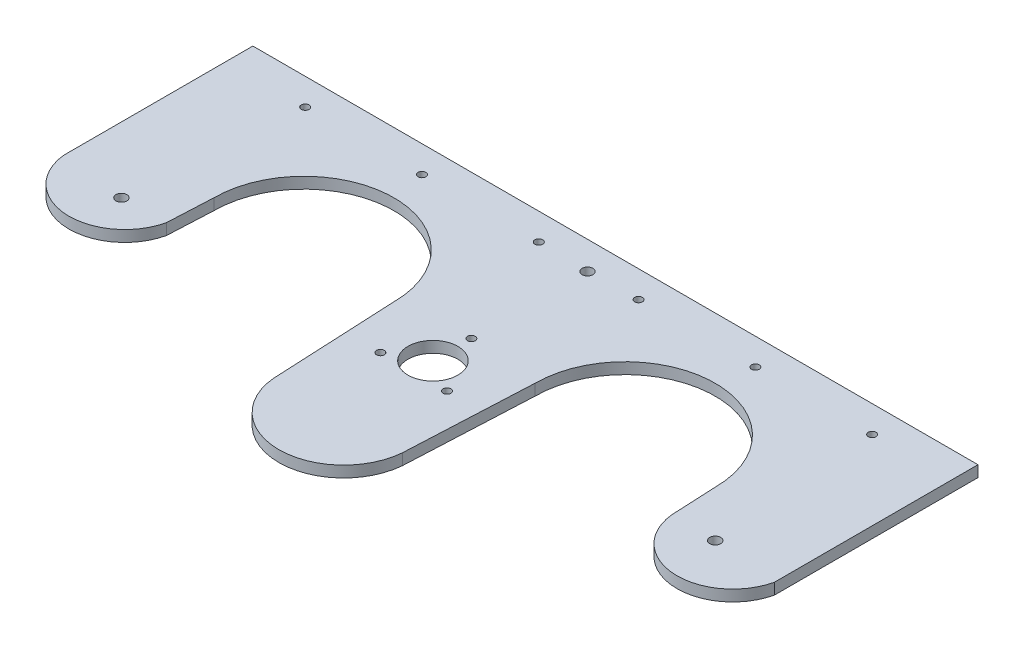
from build123d import *

# Parameters (mm, degrees)
ESQUISSE2_W                = 298
ESQUISSE2_H                = 145
BOSS_EXTRU_1_DEPTH         = 4.6
CREUX_STOCKAGE_VERRE_DEPTH = 46.6
ESQUISSE6_R                = 10.25
TROU_BILLE_DEPTH           = 5.6
ESQUISSE7_R                = 1.6
ENL_V_MAT_EXTRU_3_DEPTH    = 5.6
ENL_V_MAT_EXTRU_7_DEPTH    = 29
ESQUISSE13_R               = 2.25
ENL_V_MAT_EXTRU_9_DEPTH    = 35
ESQUISSE17_R               = 1.6
ENL_V_MAT_EXTRU_14_DEPTH   = 4.6
BOSS_EXTRU_5_DEPTH         = 4.6
ENL_V_MAT_EXTRU_15_DEPTH   = 4.6
ENL_V_MAT_EXTRU_16_DEPTH   = 4.6


with BuildPart() as part:
    # Esquisse2 → Boss.-Extru.1 (new body)
    with BuildSketch(Plane(origin=(0, 0, 0), x_dir=(1, 0, 0), z_dir=(0, 1, 0))):
        with Locations((149, 72.5)):
            Rectangle(ESQUISSE2_W, ESQUISSE2_H)
    extrude(amount=BOSS_EXTRU_1_DEPTH)

    # Esquisse3 → creux_stockage_verre (cut)
    with BuildSketch(Plane(origin=(0, 4.6, 0), x_dir=(1, 0, 0), z_dir=(0, 1, 0))):
        with BuildLine():
            Line((46, 83), (42, 0))
            Line((42, 0), (124, 0))
            Line((124, 0), (120, 83))
            ThreePointArc((120, 83), (83, 120), (46, 83))
        make_face()
        with BuildLine():
            Line((174, 0), (256, 0))
            Line((256, 0), (252, 83))
            ThreePointArc((252, 83), (215, 120), (178, 83))
            Line((178, 83), (174, 0))
        make_face()
    extrude(amount=-CREUX_STOCKAGE_VERRE_DEPTH, mode=Mode.SUBTRACT)

    # Esquisse6 → trou_bille (cut, through all)
    with BuildSketch(Plane(origin=(0, 4.6, 0), x_dir=(1, 0, 0), z_dir=(0, 1, 0))):
        with Locations((149, 70)):
            Circle(ESQUISSE6_R)
    extrude(amount=-TROU_BILLE_DEPTH, mode=Mode.SUBTRACT)

    # Esquisse7 → Enlèv. mat.-Extru.3 (cut, through all)
    with BuildSketch(Plane(origin=(0, 4.6, 0), x_dir=(1, 0, 0), z_dir=(0, 1, 0))):
        with Locations((32.5, 134)):
            Circle(ESQUISSE7_R)
        with Locations((80.5, 134)):
            Circle(ESQUISSE7_R)
        with Locations((128.5, 134)):
            Circle(ESQUISSE7_R)
        with Locations((217.5, 134)):
            Circle(ESQUISSE7_R)
        with Locations((169.5, 134)):
            Circle(ESQUISSE7_R)
        with Locations((265.5, 134)):
            Circle(ESQUISSE7_R)
    extrude(amount=-ENL_V_MAT_EXTRU_3_DEPTH, mode=Mode.SUBTRACT)

    # Esquisse9 → Enlèv. mat.-Extru.7 (cut)
    with BuildSketch(Plane(origin=(0, 4.6, 0), x_dir=(1, 0, 0), z_dir=(0, 1, 0))):
        with BuildLine():
            Line((123.101131567, 18.651519988), (120.058616356, -9.942070174))
            Line((120.058616356, -9.942070174), (178.789756957, -9.942070174))
            Line((178.789756957, -9.942070174), (174.898868433, 18.651519988))
            ThreePointArc((174.898868433, 18.651519988), (149, 12.489846239), (123.101131567, 18.651519988))
        make_face()
    extrude(amount=-ENL_V_MAT_EXTRU_7_DEPTH, mode=Mode.SUBTRACT)

    # Esquisse13 → Enlèv. mat.-Extru.9 (cut)
    with BuildSketch(Plane(origin=(0, 4.6, 0), x_dir=(1, 0, 0), z_dir=(0, 1, 0))):
        with Locations((27, 64)):
            Circle(ESQUISSE13_R)
        with Locations((271, 64)):
            Circle(ESQUISSE13_R)
        with Locations((149, 133.519410546)):
            Circle(ESQUISSE13_R)
    extrude(amount=-ENL_V_MAT_EXTRU_9_DEPTH, mode=Mode.SUBTRACT)

    # Esquisse17 → Enlèv. mat.-Extru.14 (cut)
    with BuildSketch(Plane(origin=(0, 4.6, 0), x_dir=(1, 0, 0), z_dir=(0, 1, 0))):
        with Locations((149, 85.81)):
            Circle(ESQUISSE17_R)
        with Locations((135.308138366, 62.095)):
            Circle(ESQUISSE17_R)
        with Locations((162.691861634, 62.095)):
            Circle(ESQUISSE17_R)
    extrude(amount=-ENL_V_MAT_EXTRU_14_DEPTH, mode=Mode.SUBTRACT)

    # Esquisse15 → Boss.-Extru.5 (add)
    with BuildSketch(Plane(origin=(0, 4.6, 0), x_dir=(1, 0, 0), z_dir=(0, 1, 0))):
        with BuildLine():
            ThreePointArc((175.493975904, 31), (149, 6), (122.506024096, 31))
            ThreePointArc((122.506024096, 31), (149, 25.792591017), (175.493975904, 31))
        make_face()
    extrude(amount=-BOSS_EXTRU_5_DEPTH)

    # Esquisse18 → Enlèv. mat.-Extru.15 (cut)
    with BuildSketch(Plane(origin=(0, 4.6, 0), x_dir=(1, 0, 0), z_dir=(0, 1, 0))):
        with BuildLine():
            Line((175.493975904, 31), (178.847567105, -7.009778322))
            Line((178.847567105, -7.009778322), (115.973210985, -7.009778322))
            Line((115.973210985, -7.009778322), (122.506024096, 31))
            ThreePointArc((122.506024096, 31), (149, 6.694262171), (175.493975904, 31))
        make_face()
    extrude(amount=-ENL_V_MAT_EXTRU_15_DEPTH, mode=Mode.SUBTRACT)

    # Esquisse14 → Enlèv. mat.-Extru.16 (cut)
    with BuildSketch(Plane(origin=(0, 4.6, 0), x_dir=(1, 0, 0), z_dir=(0, 1, 0))):
        with BuildLine():
            Line((0, 71.707789669), (-22.158835411, -9.528975932))
            Line((-22.158835411, -9.528975932), (50.380974376, -9.528975932))
            Line((50.380974376, -9.528975932), (45.101419153, 64.354447432))
            ThreePointArc((45.101419153, 64.354447432), (19.112822484, 46.944980874), (0, 71.707789669))
        make_face()
        with BuildLine():
            Line((252.898580847, 64.354447432), (243.707235712, -12.373693019))
            Line((243.707235712, -12.373693019), (332.150206643, -12.373693019))
            Line((332.150206643, -12.373693019), (298, 71.707789669))
            ThreePointArc((298, 71.707789669), (279.381330699, 43.914112857), (252.898580847, 64.354447432))
        make_face()
    extrude(amount=-ENL_V_MAT_EXTRU_16_DEPTH, mode=Mode.SUBTRACT)


solid = part.part
